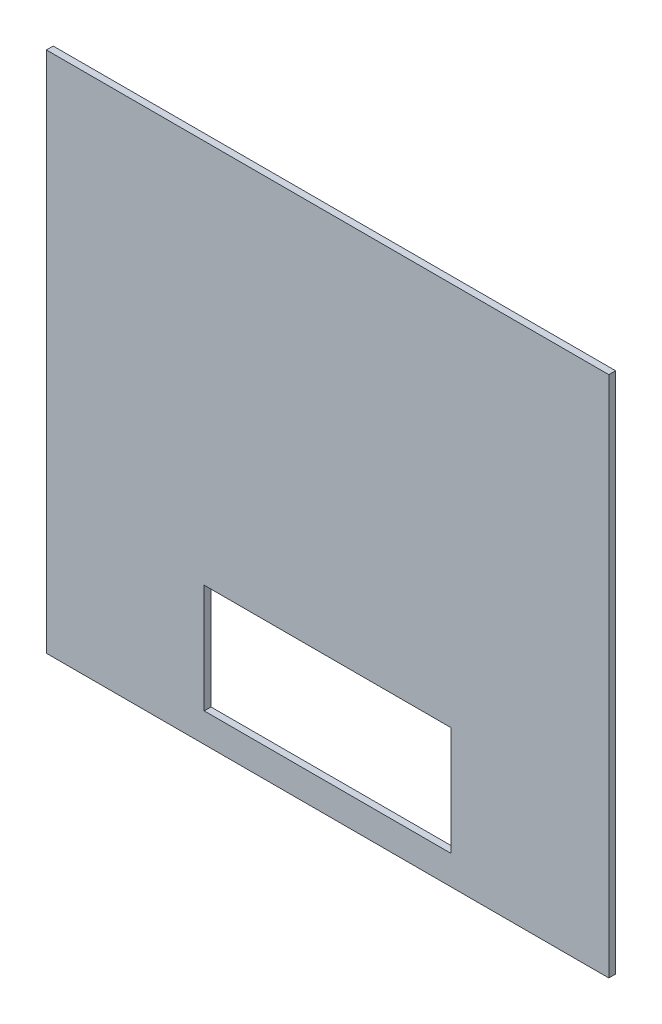
from build123d import *

# Parameters (mm, degrees)
SKETCH1_W               = 984.25
SKETCH1_H               = 914.4
BOSS_EXTRUDE1_DEPTH     = 11.90625
CUT_EXTRUDE1_DEPTH      = 1
CUT_EXTRUDE1_DEPTH_BACK = 12.90625


with BuildPart() as part:
    # Sketch1 → Boss-Extrude1 (new body)
    with BuildSketch(Plane.XY):
        Rectangle(SKETCH1_W, SKETCH1_H)
    extrude(amount=BOSS_EXTRUDE1_DEPTH)

    # Sketch3 → Cut-Extrude1 (cut, two sides)
    with BuildSketch(Plane.XY.offset(11.90625)) as cut_extrude1_sk:
        Polygon((0, -406.4), (215.9, -406.4), (215.9, -215.9), (-215.9, -215.9), (-215.9, -406.4), align=None)
    extrude(amount=CUT_EXTRUDE1_DEPTH, mode=Mode.SUBTRACT)
    extrude(cut_extrude1_sk.sketch, amount=-CUT_EXTRUDE1_DEPTH_BACK, mode=Mode.SUBTRACT)


solid = part.part
